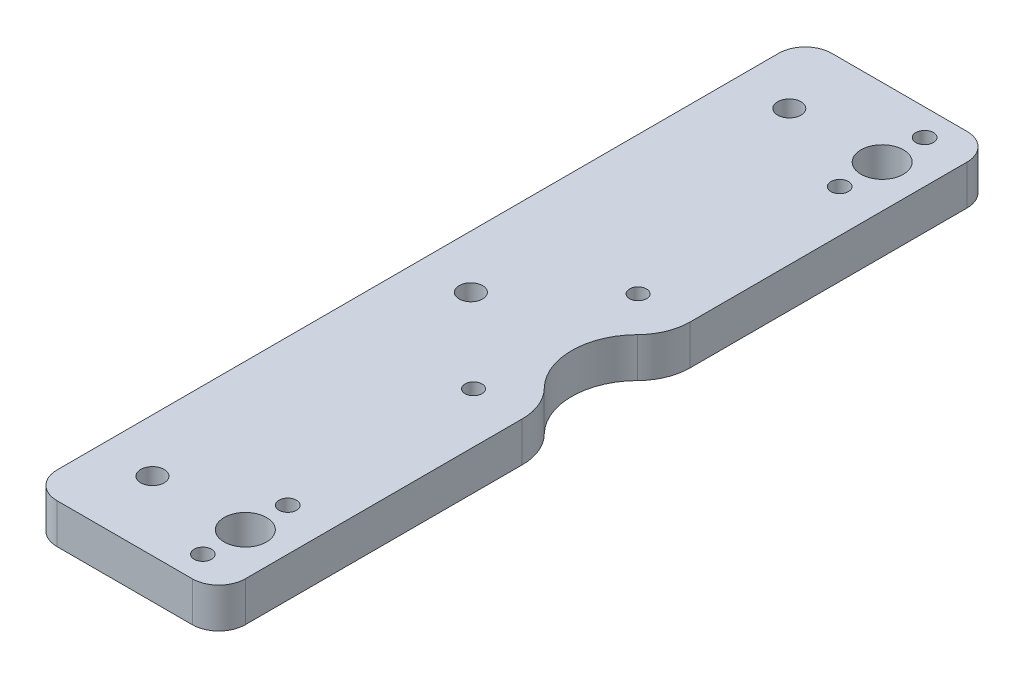
from build123d import *

# Parameters (mm, degrees)
SKETCH1_R           = 1.65
SKETCH1_R_2         = 1.6
SKETCH1_R_3         = 2.2
SKETCH1_R_4         = 4
BOSS_EXTRUDE1_DEPTH = 7.5


with BuildPart() as part:
    # Sketch1 → Boss-Extrude1 (new body)
    with BuildSketch(Plane(origin=(0, 3.75, 0), x_dir=(1, 0, 0), z_dir=(0, 1, 0))):
        with BuildLine():
            Line((8, -68), (8, -15.81929202))
            ThreePointArc((8, -15.81929202), (7.249624617, -12.018707269), (5.111111111, -8.788495566))
            ThreePointArc((5.111111111, -8.788495566), (1.5, 0), (5.111111111, 8.788495566))
            ThreePointArc((5.111111111, 8.788495566), (7.249624617, 12.018707269), (8, 15.81929202))
            Line((8, 15.81929202), (8, 68))
            ThreePointArc((8, 68), (6.535533906, 71.535533906), (3, 73))
            Line((3, 73), (-22.5, 73))
            ThreePointArc((-22.5, 73), (-26.035533906, 71.535533906), (-27.5, 68))
            Line((-27.5, 68), (-27.5, -68))
            ThreePointArc((-27.5, -68), (-26.035533906, -71.535533906), (-22.5, -73))
            Line((-22.5, -73), (3, -73))
            ThreePointArc((3, -73), (6.535533906, -71.535533906), (8, -68))
        make_face()
        with Locations((0, -68)):
            Circle(SKETCH1_R, mode=Mode.SUBTRACT)
        with Locations((0, -52)):
            Circle(SKETCH1_R, mode=Mode.SUBTRACT)
        with Locations((0, 68)):
            Circle(SKETCH1_R, mode=Mode.SUBTRACT)
        with Locations((0, 52)):
            Circle(SKETCH1_R, mode=Mode.SUBTRACT)
        with Locations((-1.5, 15.5)):
            Circle(SKETCH1_R_2, mode=Mode.SUBTRACT)
        with Locations((-1.5, -15.5)):
            Circle(SKETCH1_R_2, mode=Mode.SUBTRACT)
        with Locations((-17.5, 0)):
            Circle(SKETCH1_R_3, mode=Mode.SUBTRACT)
        with Locations((0, -60)):
            Circle(SKETCH1_R_4, mode=Mode.SUBTRACT)
        with Locations((0, 60)):
            Circle(SKETCH1_R_4, mode=Mode.SUBTRACT)
        with Locations((-17.5, 60)):
            Circle(SKETCH1_R_3, mode=Mode.SUBTRACT)
        with Locations((-17.5, -60)):
            Circle(SKETCH1_R_3, mode=Mode.SUBTRACT)
    extrude(amount=-BOSS_EXTRUDE1_DEPTH)


solid = part.part
